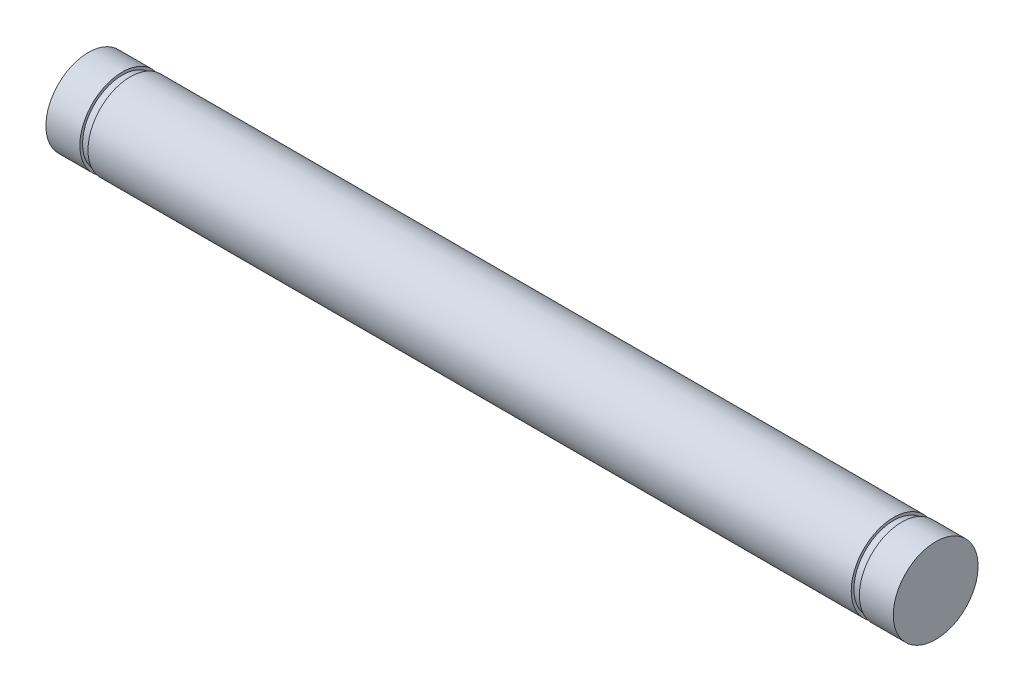
from build123d import *

# Parameters (mm, degrees)
SKETCH2_R               = 1.5875
EXTRUDE1_DEPTH          = 25.4
EXTRUDE1_DEPTH_BACK     = 25.4
CHAMFER1_SIZE           = 0.3175
SKETCH3_OUTSIDE_W       = 15.376
SKETCH3_OUTSIDE_H       = 15.376
SKETCH3_OUTSIDE_R       = 1.4859
CUT_EXTRUDE1_DEPTH      = 0.3048
SKETCH4_OUTSIDE_W       = 15.376
SKETCH4_OUTSIDE_H       = 15.376
SKETCH4_OUTSIDE_R       = 1.4859
CUT_EXTRUDE2_DEPTH      = 0.3048
SKETCH5_W               = 17.4752
SKETCH5_H               = 6.35
SKETCH5_W_2             = 1.6002
CUT_EXTRUDE3_DEPTH      = 2.5875
CUT_EXTRUDE3_DEPTH_BACK = 2.5875


with BuildPart() as part:
    # Sketch2 → Extrude1 (new body, two sides)
    with BuildSketch(Plane(origin=(0, 0, 0), x_dir=(0, 0, -1), z_dir=(1, 0, 0))) as extrude1_sk:
        Circle(SKETCH2_R)
    extrude(amount=EXTRUDE1_DEPTH)
    extrude(extrude1_sk.sketch, amount=-EXTRUDE1_DEPTH_BACK)

    # Chamfer1
    chamfer1_edges = [part.edges().sort_by_distance(p)[0] for p in [
        (-25.4, 0, 1.5875),
        (25.4, 0, 1.5875),
    ]]
    chamfer(chamfer1_edges, length=CHAMFER1_SIZE)

    # Sketch3 outside → Cut-Extrude1 (cut)
    with BuildSketch(Plane.ZY.offset(22.225)):
        Rectangle(SKETCH3_OUTSIDE_W, SKETCH3_OUTSIDE_H)
        Circle(SKETCH3_OUTSIDE_R, mode=Mode.SUBTRACT)
    extrude(amount=CUT_EXTRUDE1_DEPTH, mode=Mode.SUBTRACT)

    # Sketch4 outside → Cut-Extrude2 (cut)
    with BuildSketch(Plane.ZY.offset(-6.35)):
        Rectangle(SKETCH4_OUTSIDE_W, SKETCH4_OUTSIDE_H)
        Circle(SKETCH4_OUTSIDE_R, mode=Mode.SUBTRACT)
    extrude(amount=-CUT_EXTRUDE2_DEPTH, mode=Mode.SUBTRACT)

    # Sketch5 → Cut-Extrude3 (cut, two sides)
    with BuildSketch(Plane.XY) as cut_extrude3_sk:
        with Locations((16.6624, 0)):
            Rectangle(SKETCH5_W, SKETCH5_H)
        with Locations((-24.5999, 0)):
            Rectangle(SKETCH5_W_2, SKETCH5_H)
    extrude(amount=CUT_EXTRUDE3_DEPTH, mode=Mode.SUBTRACT)
    extrude(cut_extrude3_sk.sketch, amount=-CUT_EXTRUDE3_DEPTH_BACK, mode=Mode.SUBTRACT)


solid = part.part
